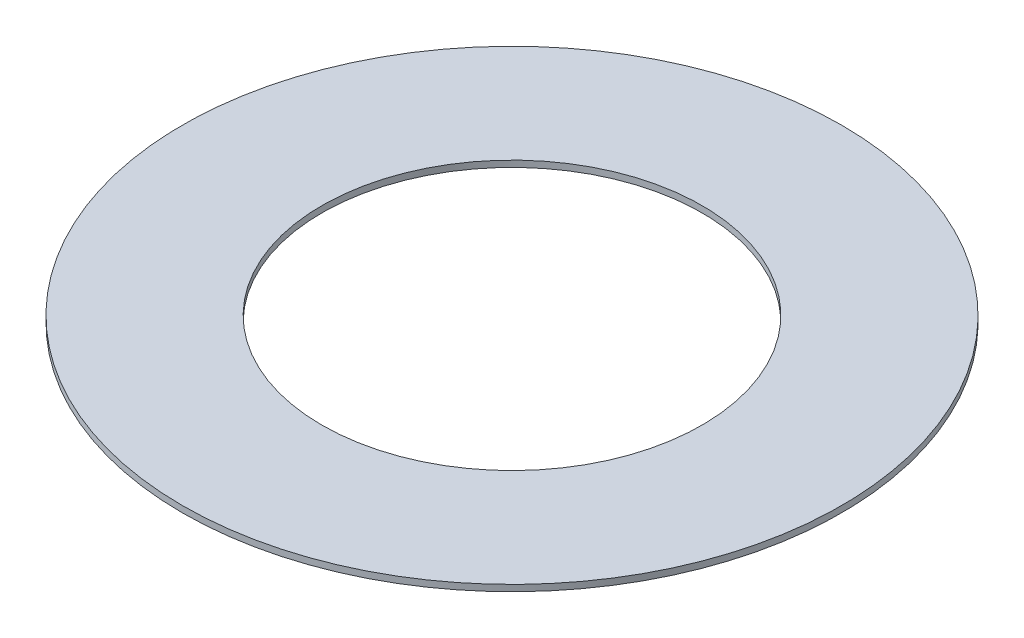
from build123d import *

# Parameters (mm, degrees)
SKETCH2_R           = 66.04
SKETCH2_R_2         = 38.1
BOSS_EXTRUDE1_DEPTH = 1.27


with BuildPart() as part:
    # Sketch2 → Boss-Extrude1 (new body)
    with BuildSketch(Plane(origin=(0, 0, 0), x_dir=(1, 0, 0), z_dir=(0, 1, 0))):
        Circle(SKETCH2_R)
        Circle(SKETCH2_R_2, mode=Mode.SUBTRACT)
    extrude(amount=BOSS_EXTRUDE1_DEPTH)


solid = part.part
